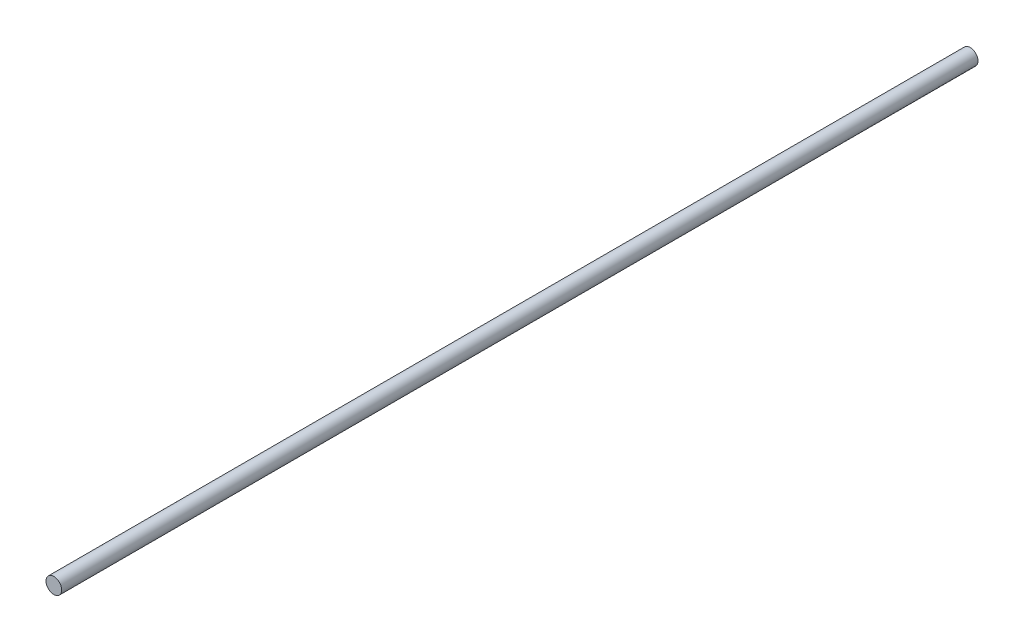
from build123d import *

# Parameters (mm, degrees)
SKETCH1_R           = 3.175
BOSS_EXTRUDE1_DEPTH = 370.84


with BuildPart() as part:
    # Sketch1 → Boss-Extrude1 (new body)
    with BuildSketch(Plane.XY):
        Circle(SKETCH1_R)
    extrude(amount=BOSS_EXTRUDE1_DEPTH)


solid = part.part
